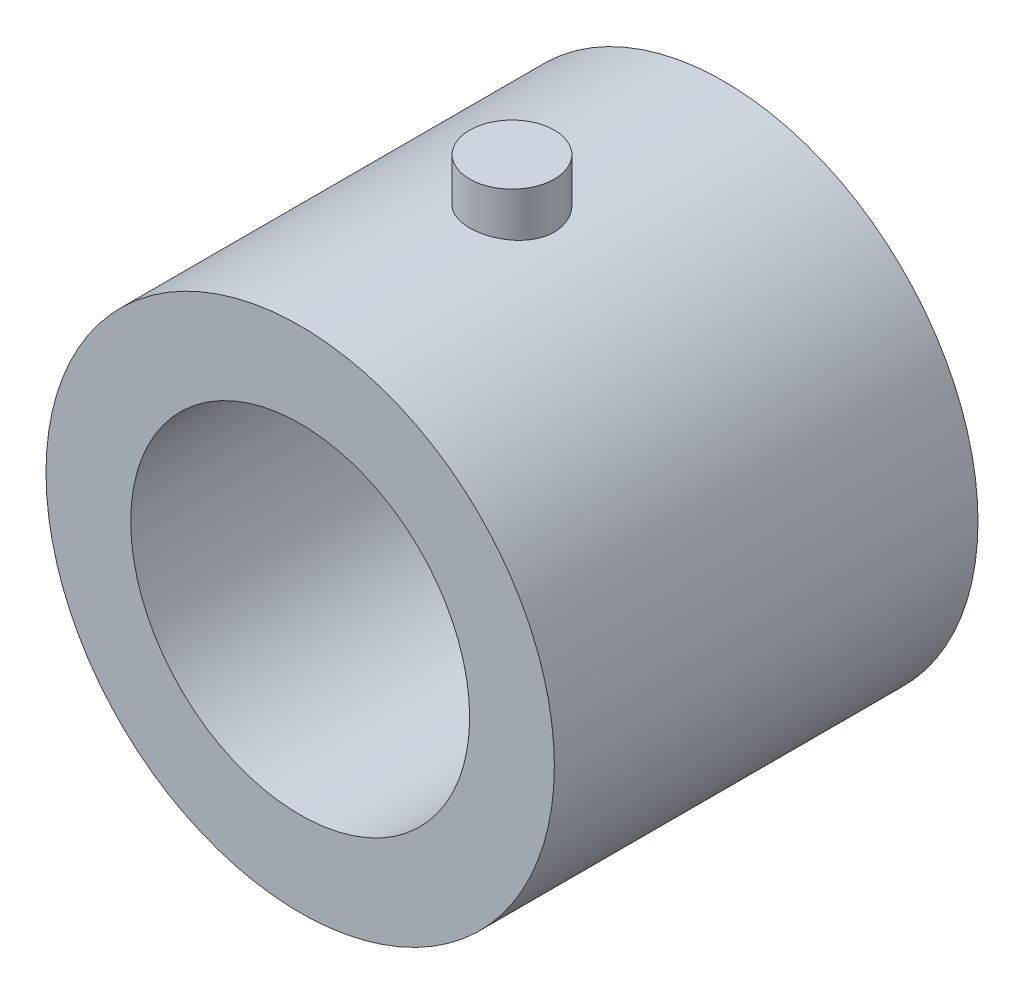
from build123d import *

# Parameters (mm, degrees)
SKETCH_1_R          = 3
SKETCH_1_R_2        = 2
EXTRUDE_1_DEPTH     = 5
SKETCH_2_R          = 0.5
EXTRUDE_2_DEPTH     = 3.5
SKETCH_3_R          = 2
CUT_EXTRUDE_1_DEPTH = 3.5


with BuildPart() as part:
    # 草图1 → 凸台-拉伸1 (new body)
    with BuildSketch(Plane.XY):
        Circle(SKETCH_1_R)
        Circle(SKETCH_1_R_2, mode=Mode.SUBTRACT)
    extrude(amount=EXTRUDE_1_DEPTH)

    # 草图2 → 凸台-拉伸2 (add)
    with BuildSketch(Plane(origin=(0, 0, 0), x_dir=(1, 0, 0), z_dir=(0, 1, 0))):
        with Locations((0, -2.5)):
            Circle(SKETCH_2_R)
    extrude(amount=EXTRUDE_2_DEPTH)

    # 草图3 → 切除-拉伸1 (cut)
    with BuildSketch(Plane.XY.offset(5)):
        Circle(SKETCH_3_R)
    extrude(amount=-CUT_EXTRUDE_1_DEPTH, mode=Mode.SUBTRACT)


solid = part.part
